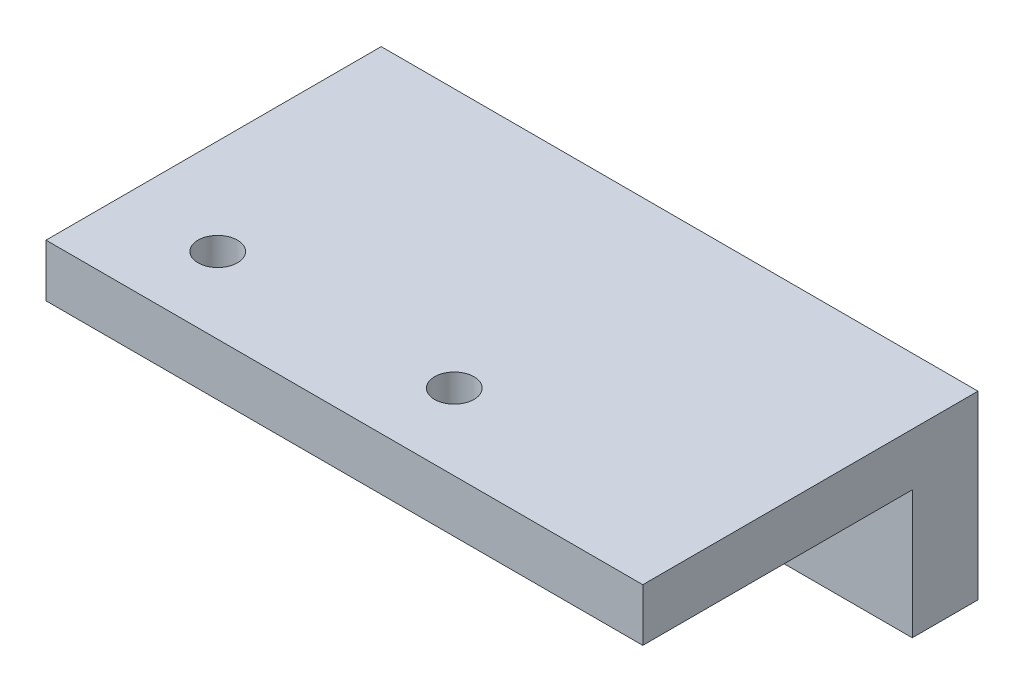
from build123d import *

# Parameters (mm, degrees)
SKETCH1_W           = 45.4
SKETCH1_H           = 25.5
BOSS_EXTRUDE1_DEPTH = 4
SKETCH2_W           = 45.4
SKETCH2_H           = 5
BOSS_EXTRUDE2_DEPTH = 9.75
SKETCH3_R           = 1.5
CUT_EXTRUDE1_DEPTH  = 10
SKETCH7_R           = 1.65
CUT_EXTRUDE3_DEPTH  = 10


with BuildPart() as part:
    # Sketch1 → Boss-Extrude1 (new body)
    with BuildSketch(Plane(origin=(0, 0, 0), x_dir=(1, 0, 0), z_dir=(0, 1, 0))):
        with Locations((22.7, 12.75)):
            Rectangle(SKETCH1_W, SKETCH1_H)
    extrude(amount=BOSS_EXTRUDE1_DEPTH)

    # Sketch2 → Boss-Extrude2 (add)
    with BuildSketch(Plane.XZ):
        with Locations((22.7, -23)):
            Rectangle(SKETCH2_W, SKETCH2_H)
    extrude(amount=BOSS_EXTRUDE2_DEPTH)

    # Sketch3 → Cut-Extrude1 (cut)
    with BuildSketch(Plane(origin=(0, 4, 0), x_dir=(1, 0, 0), z_dir=(0, 1, 0))):
        with Locations((7.278895007, 5.784390941)):
            Circle(SKETCH3_R)
        with Locations((25.277013577, 5.782705683)):
            Circle(SKETCH3_R)
    extrude(amount=-CUT_EXTRUDE1_DEPTH, mode=Mode.SUBTRACT)

    # Sketch7 → Cut-Extrude3 (cut)
    with BuildSketch(Plane.XY.offset(-20.5)):
        with Locations((32.4, -4.881628377)):
            Circle(SKETCH7_R)
        with Locations((13, -4.881628377)):
            Circle(SKETCH7_R)
    extrude(amount=-CUT_EXTRUDE3_DEPTH, mode=Mode.SUBTRACT)


solid = part.part
